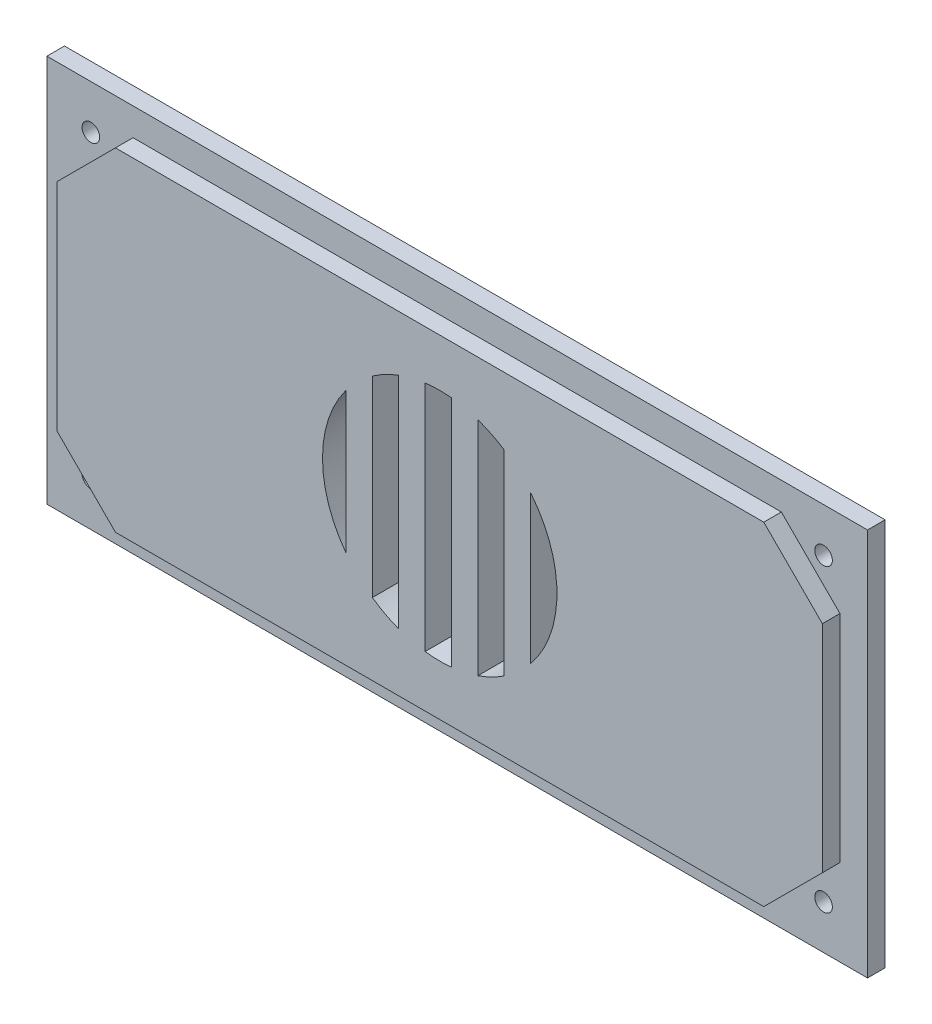
from build123d import *

# Parameters (mm, degrees)
SKETCH2_W           = 140
SKETCH2_H           = 66.2
BOSS_EXTRUDE1_DEPTH = 3
SKETCH3_W           = 130.6
SKETCH3_H           = 56.8
BOSS_EXTRUDE2_DEPTH = 3
CUT_EXTRUDE1_DEPTH  = 7
SKETCH5_R           = 1.5
CUT_EXTRUDE2_DEPTH  = 7
CUT_EXTRUDE3_DEPTH  = 3


with BuildPart() as part:
    # Sketch2 → Boss-Extrude1 (new body)
    with BuildSketch(Plane.XY):
        Rectangle(SKETCH2_W, SKETCH2_H)
    extrude(amount=-BOSS_EXTRUDE1_DEPTH)

    # Sketch3 → Boss-Extrude2 (add)
    with BuildSketch(Plane.XY):
        Rectangle(SKETCH3_W, SKETCH3_H)
    extrude(amount=BOSS_EXTRUDE2_DEPTH)

    # Sketch4 → Cut-Extrude1 (cut, through all)
    with BuildSketch(Plane(origin=(0, 0, -3), x_dir=(-1, 0, 0), z_dir=(0, 0, -1))):
        with BuildLine():
            ThreePointArc((-15.519758089, 12.871012345), (-18.86120177, 6.939991617), (-20.019758089, 0.231787685))
            ThreePointArc((-20.019758089, 0.231787685), (-18.86120177, -6.476416248), (-15.519758089, -12.407436975))
            Line((-15.519758089, -12.407436975), (-15.519758089, 12.871012345))
        make_face()
        with BuildLine():
            ThreePointArc((-6.519758089, 19.146068004), (-8.839316816, 18.182146563), (-11.019758089, 16.935080773))
            Line((-11.019758089, 16.935080773), (-11.019758089, -16.471505404))
            ThreePointArc((-11.019758089, -16.471505404), (-8.839316816, -17.718571194), (-6.519758089, -18.682492635))
            Line((-6.519758089, -18.682492635), (-6.519758089, 19.146068004))
        make_face()
        with BuildLine():
            ThreePointArc((2.480241911, 20.074922518), (1.232700165, 20.192532869), (-0.019758083, 20.231787685))
            ThreePointArc((-0.019758083, 20.231787685), (-1.021013587, 20.206709147), (-2.019758089, 20.131536427))
            Line((-2.019758089, 20.131536427), (-2.019758089, -19.667961057))
            ThreePointArc((-2.019758089, -19.667961057), (-1.02101359, -19.743133777), (-0.019758089, -19.768212315))
            ThreePointArc((-0.019758089, -19.768212315), (1.232700162, -19.7289575), (2.480241911, -19.611347148))
            Line((2.480241911, -19.611347148), (2.480241911, 20.074922518))
        make_face()
        with BuildLine():
            ThreePointArc((11.480241911, 16.594855857), (9.305959472, 17.924469561), (6.980241911, 18.96678168))
            Line((6.980241911, 18.96678168), (6.980241911, -18.50320631))
            ThreePointArc((6.980241911, -18.50320631), (9.305959472, -17.460894191), (11.480241911, -16.131280487))
            Line((11.480241911, -16.131280487), (11.480241911, 16.594855857))
        make_face()
        with BuildLine():
            ThreePointArc((19.980241911, 0.231787685), (18.953907872, 6.556343005), (15.980241911, 12.231787685))
            Line((15.980241911, 12.231787685), (15.980241911, -11.768212315))
            ThreePointArc((15.980241911, -11.768212315), (18.953907872, -6.092767635), (19.980241911, 0.231787685))
        make_face()
    extrude(amount=-CUT_EXTRUDE1_DEPTH, mode=Mode.SUBTRACT)

    # Sketch5 → Cut-Extrude2 (cut, through all)
    with BuildSketch(Plane(origin=(0, 0, -3), x_dir=(-1, 0, 0), z_dir=(0, 0, -1))):
        with Locations((-62.5, 25.6)):
            Circle(SKETCH5_R)
        with Locations((62.5, 25.6)):
            Circle(SKETCH5_R)
        with Locations((62.5, -25.6)):
            Circle(SKETCH5_R)
        with Locations((-62.5, -25.6)):
            Circle(SKETCH5_R)
    extrude(amount=-CUT_EXTRUDE2_DEPTH, mode=Mode.SUBTRACT)

    # Sketch6 → Cut-Extrude3 (cut)
    with BuildSketch(Plane.XY.offset(3)):
        Polygon((65.3, 28.4), (55.3, 28.4), (65.3, 18.4), align=None)
        Polygon((65.3, -28.4), (65.3, -18.4), (55.3, -28.4), align=None)
        Polygon((-65.3, -28.4), (-55.3, -28.4), (-65.3, -18.4), align=None)
        Polygon((-65.3, 28.4), (-65.3, 18.4), (-55.3, 28.4), align=None)
    extrude(amount=-CUT_EXTRUDE3_DEPTH, mode=Mode.SUBTRACT)


solid = part.part
